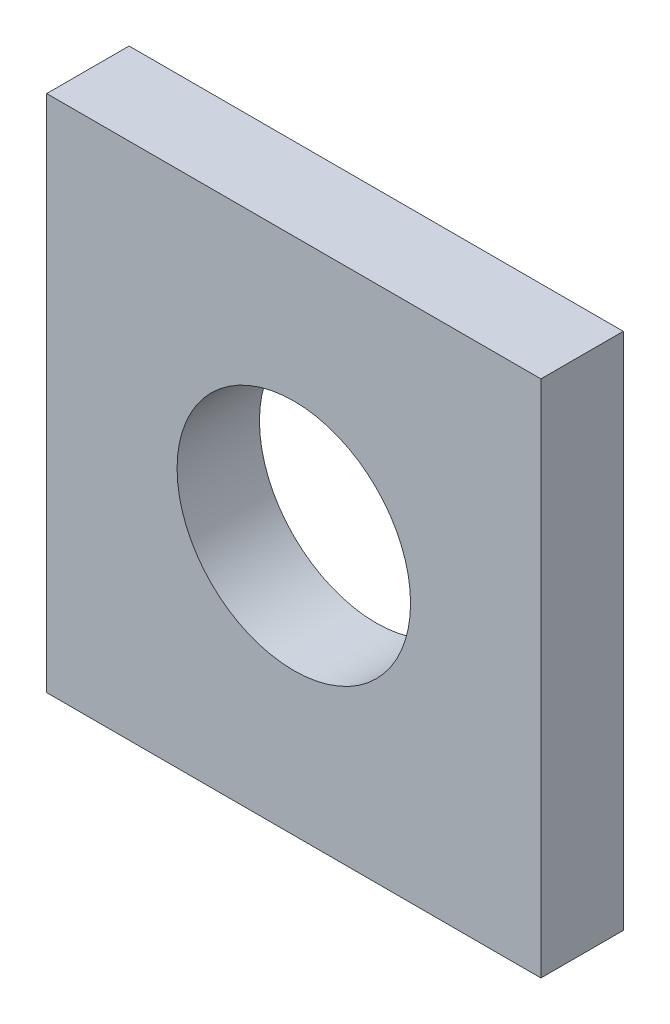
from build123d import *

# Parameters (mm, degrees)
SKETCH1_W                                = 19.05
SKETCH1_H                                = 20
BOSS_EXTRUDE1_DEPTH                      = 3.175
CELL_MODULE_TERMINAL_M8_CLEARANCE_HOLE_D = 9


with BuildPart() as part:
    # Sketch1 → Boss-Extrude1 (new body)
    with BuildSketch(Plane.XY):
        with Locations((-17, 0)):
            Rectangle(SKETCH1_W, SKETCH1_H)
    extrude(amount=BOSS_EXTRUDE1_DEPTH)

    # Cell Module Terminal M8 Clearance Hole (through all)
    with Locations(Plane.XY.offset(3.175)):
        with Locations((-17, 0)):
            Hole(CELL_MODULE_TERMINAL_M8_CLEARANCE_HOLE_D / 2)


solid = part.part
